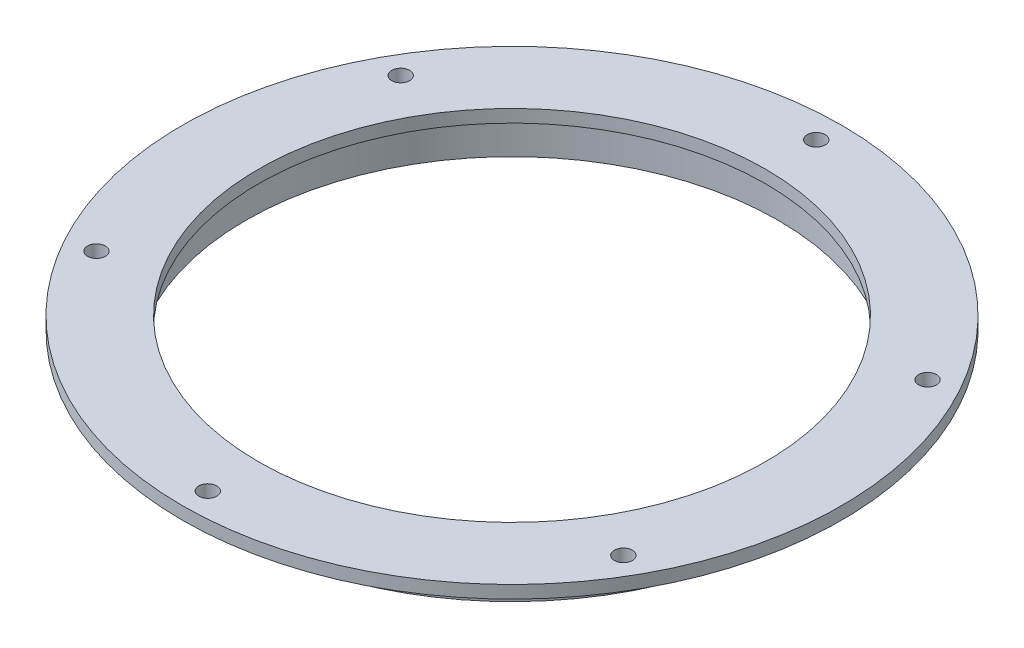
from build123d import *

# Parameters (mm, degrees)
F_8_CLEARANCE_HOLE1_D     = 4.4958
F_8_CLEARANCE_HOLE1_DEPTH = 3.176
CIRPATTERN1_COUNT         = 6
SKETCH4_R                 = 63.5
CUT_EXTRUDE1_DEPTH        = 13.7


with BuildPart() as part:
    # Sketch1 → Revolve1 (revolve)
    with BuildSketch(Plane(origin=(0, 0, 0), x_dir=(0, 0, -1), z_dir=(1, 0, 0))):
        Polygon((66.675, 0), (69.85, 0), (69.85, 9.525), (82.55, 9.525), (82.55, 12.7), (0, 12.7), (0, 9.525), (66.675, 9.525), align=None)
    revolve(axis=Axis((0, 0, 0), (0, 1, 0)))

    # #8 Clearance Hole1
    with Locations(Plane(origin=(0, 12.7, 0), x_dir=(1, 0, 0), z_dir=(0, 1, 0))):
        with Locations((0, 76.2)):
            f_8_clearance_hole1 = Hole(F_8_CLEARANCE_HOLE1_D / 2, depth=F_8_CLEARANCE_HOLE1_DEPTH)

    # CirPattern1: #8 Clearance Hole1 ×6 about axis
    cirpattern1_axis = Axis((0, 0, 0), (0, 1, 0))
    for i in range(1, CIRPATTERN1_COUNT):
        add(f_8_clearance_hole1.rotate(cirpattern1_axis, i * 360 / CIRPATTERN1_COUNT), mode=Mode.SUBTRACT)

    # Sketch4 → Cut-Extrude1 (cut, through all)
    with BuildSketch(Plane(origin=(0, 12.7, 0), x_dir=(1, 0, 0), z_dir=(0, 1, 0))):
        Circle(SKETCH4_R)
    extrude(amount=-CUT_EXTRUDE1_DEPTH, mode=Mode.SUBTRACT)


solid = part.part
